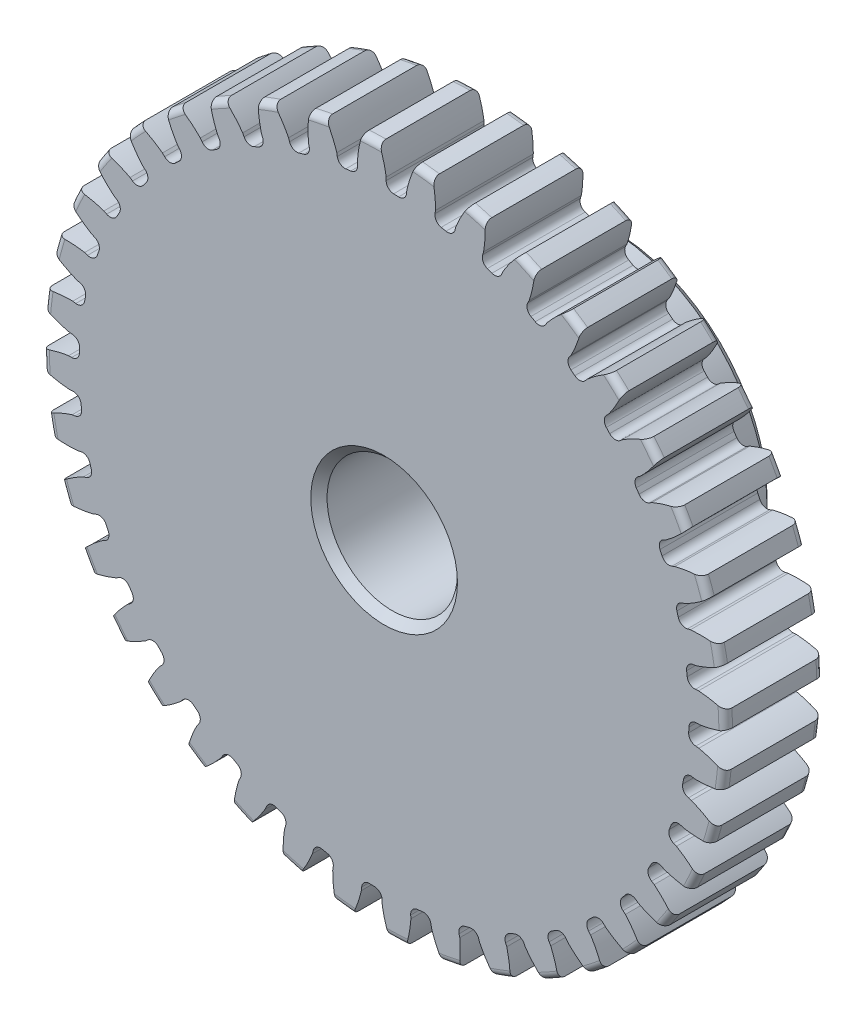
from build123d import *

# Parameters (mm, degrees)
SKETCH1_R                = 16.637
BOSS_EXTRUDE1_DEPTH      = 4.7625
SKETCH2_W                = 6.35
SKETCH2_H                = 7.9375
FILLET2_R                = 0.33274
CUT_EXTRUDE1_DEPTH       = 12.1125
FILLET1_R                = 0.37404675
CIRPATTERN1_COUNT        = 40
FILLET1_OF_CIRPATTERN1_R = 0.37404675
SKETCH5_R                = 3.175
CUT_EXTRUDE2_DEPTH       = 12.1125
CHAMFER1_SIZE            = 0.396875


with BuildPart() as part:
    # Sketch1 → Boss-Extrude1 (new body)
    with BuildSketch(Plane.XY):
        Circle(SKETCH1_R)
    extrude(amount=-BOSS_EXTRUDE1_DEPTH)

    # Sketch2 → Revolve1 (revolve)
    with BuildSketch(Plane(origin=(0, 0, 0), x_dir=(0, 0, -1), z_dir=(1, 0, 0))):
        with Locations((7.9375, 3.96875)):
            Rectangle(SKETCH2_W, SKETCH2_H)
    revolve(axis=Axis((0, 0, -4.7625), (0, 0, -1)))

    # Fillet2
    fillet2_edges = [part.edges().sort_by_distance(p)[0] for p in [
        (-16.637, 0, 0),
        (-16.637, 0, -4.7625),
        (0, -7.9375, -4.7625),
    ]]
    fillet(fillet2_edges, radius=FILLET2_R)

    # Sketch4 → Cut-Extrude1 (cut, through all)
    with BuildSketch(Plane.XY):
        with BuildLine():
            Line((0.099855881, 15.369019402), (0.099855881, 14.85072679))
            ThreePointArc((0.099855881, 14.85072679), (0.58305134, 14.839612815), (1.065629257, 14.812781362))
            Line((1.065629257, 14.812781362), (1.106294121, 15.329476243))
            add(Edge.make_bspline(
                [(3.036161866, 18.483177992), (1.529837457, 17.142178464), (1.106294121, 15.329476243)],
                knots=[0, 0, 0, 1, 1, 1], degree=2))
            ThreePointArc((3.036161866, 18.483177992), (0.735372912, 18.716446624), (-1.576625532, 18.664415327))
            add(Edge.make_bspline(
                [(-1.576625532, 18.664415327), (-0.180158497, 17.209364545), (0.099855881, 15.369019402)],
                knots=[0, 0, 0, 1, 1, 1], degree=2))
        make_face()
    cut_extrude1 = extrude(amount=-CUT_EXTRUDE1_DEPTH, mode=Mode.SUBTRACT)

    # Fillet1
    fillet1_edges = [part.edges().sort_by_distance(p)[0] for p in [
        (1.065629257, 14.812781362, -2.38125),
        (0.099855881, 14.85072679, -2.38125),
    ]]
    fillet(fillet1_edges, radius=FILLET1_R)

    # CirPattern1: Cut-Extrude1 ×40 about axis
    cirpattern1_axis = Axis((0, 0, -4.7625), (0, 0, 1))
    for i in range(1, CIRPATTERN1_COUNT):
        add(cut_extrude1.rotate(cirpattern1_axis, i * 360 / CIRPATTERN1_COUNT), mode=Mode.SUBTRACT)

    # Fillet1 of CirPattern1
    fillet1_of_cirpattern1_edges = [part.edges().sort_by_distance(p)[0] for p in [
        (-1.264719936, 14.797112585, -2.38125),
        (-2.224539012, 14.683510601, -2.38125),
        (-3.563927526, 14.417089788, -2.38125),
        (-4.494158371, 14.154737649, -2.38125),
        (-5.775379393, 13.682070393, -2.38125),
        (-6.653116636, 13.27742808, -2.38125),
        (-7.844622251, 12.610153017, -2.38125),
        (-8.648253088, 12.073184166, -2.38125),
        (-9.720704475, 11.227731823, -2.38125),
        (-10.430440848, 10.571658389, -2.38125),
        (-11.357430694, 9.568846608, -2.38125),
        (-11.955796538, 8.809823297, -2.38125),
        (-12.714499276, 7.674344633, -2.38125),
        (-13.186760837, 6.831061118, -2.38125),
        (-13.758494688, 5.590874823, -2.38125),
        (-14.093023321, 4.684095543, -2.38125),
        (-14.4637103, 3.369739121, -2.38125),
        (-14.652268798, 2.42179199, -2.38125),
        (-14.812781362, 1.065629257, -2.38125),
        (-14.85072679, 0.099855881, -2.38125),
        (-14.797112585, -1.264719936, -2.38125),
        (-14.683510601, -2.224539012, -2.38125),
        (-14.417089788, -3.563927526, -2.38125),
        (-14.154737649, -4.494158371, -2.38125),
        (-13.682070393, -5.775379393, -2.38125),
        (-13.27742808, -6.653116636, -2.38125),
        (-12.610153017, -7.844622251, -2.38125),
        (-12.073184166, -8.648253088, -2.38125),
        (-11.227731823, -9.720704475, -2.38125),
        (-10.571658389, -10.430440848, -2.38125),
        (-9.568846608, -11.357430694, -2.38125),
        (-8.809823297, -11.955796538, -2.38125),
        (-7.674344633, -12.714499276, -2.38125),
        (-6.831061118, -13.186760837, -2.38125),
        (-5.590874823, -13.758494688, -2.38125),
        (-4.684095543, -14.093023321, -2.38125),
        (-3.369739121, -14.4637103, -2.38125),
        (-2.42179199, -14.652268798, -2.38125),
        (-1.065629257, -14.812781362, -2.38125),
        (-0.099855881, -14.85072679, -2.38125),
        (1.264719936, -14.797112585, -2.38125),
        (2.224539012, -14.683510601, -2.38125),
        (3.563927526, -14.417089788, -2.38125),
        (4.494158371, -14.154737649, -2.38125),
        (5.775379393, -13.682070393, -2.38125),
        (6.653116636, -13.27742808, -2.38125),
        (7.844622251, -12.610153017, -2.38125),
        (8.648253088, -12.073184166, -2.38125),
        (9.720704475, -11.227731823, -2.38125),
        (10.430440848, -10.571658389, -2.38125),
        (11.357430694, -9.568846608, -2.38125),
        (11.955796538, -8.809823297, -2.38125),
        (12.714499276, -7.674344633, -2.38125),
        (13.186760837, -6.831061118, -2.38125),
        (13.758494688, -5.590874823, -2.38125),
        (14.093023321, -4.684095543, -2.38125),
        (14.4637103, -3.369739121, -2.38125),
        (14.652268798, -2.42179199, -2.38125),
        (14.812781362, -1.065629257, -2.38125),
        (14.85072679, -0.099855881, -2.38125),
        (14.797112585, 1.264719936, -2.38125),
        (14.683510601, 2.224539012, -2.38125),
        (14.417089788, 3.563927526, -2.38125),
        (14.154737649, 4.494158371, -2.38125),
        (13.682070393, 5.775379393, -2.38125),
        (13.27742808, 6.653116636, -2.38125),
        (12.610153017, 7.844622251, -2.38125),
        (12.073184166, 8.648253088, -2.38125),
        (11.227731823, 9.720704475, -2.38125),
        (10.571658389, 10.430440848, -2.38125),
        (9.568846608, 11.357430694, -2.38125),
        (8.809823297, 11.955796538, -2.38125),
        (7.674344633, 12.714499276, -2.38125),
        (6.831061118, 13.186760837, -2.38125),
        (5.590874823, 13.758494688, -2.38125),
        (4.684095543, 14.093023321, -2.38125),
        (3.369739121, 14.4637103, -2.38125),
        (2.42179199, 14.652268798, -2.38125),
    ]]
    fillet(fillet1_of_cirpattern1_edges, radius=FILLET1_OF_CIRPATTERN1_R)

    # Sketch5 → Cut-Extrude2 (cut, through all)
    with BuildSketch(Plane.XY):
        Circle(SKETCH5_R)
    extrude(amount=-CUT_EXTRUDE2_DEPTH, mode=Mode.SUBTRACT)

    # Chamfer1
    chamfer1_edges = [part.edges().sort_by_distance(p)[0] for p in [
        (-3.175, 0, -11.1125),
        (-3.175, 0, 0),
        (0, -7.9375, -11.1125),
    ]]
    chamfer(chamfer1_edges, length=CHAMFER1_SIZE)


solid = part.part
